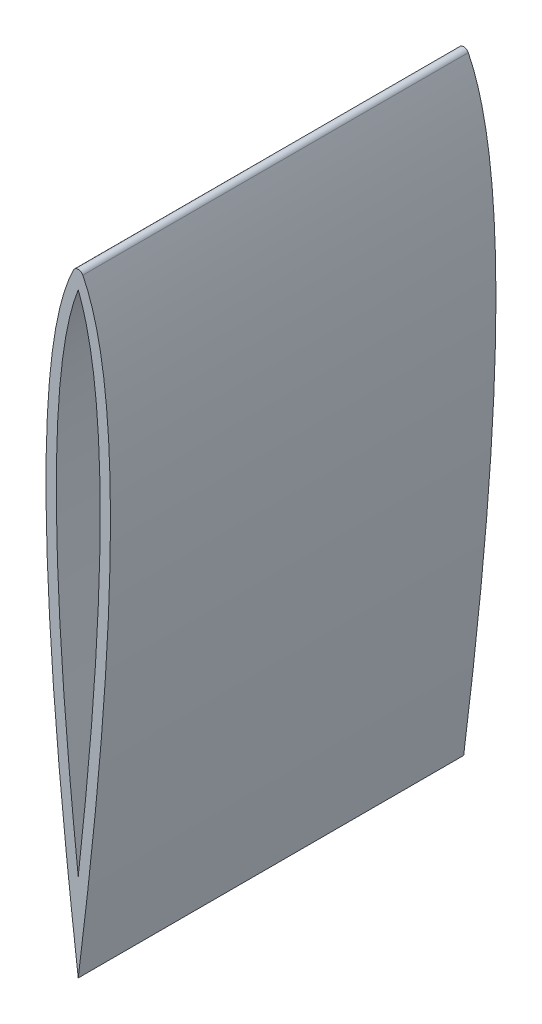
from build123d import *

# Parameters (mm, degrees)
BOSS_EXTRUDE1_DEPTH = 94.869


with BuildPart() as part:
    # Sketch1 → Boss-Extrude1 (new, symmetric)
    with BuildSketch(Plane.XY):
        with BuildLine():
            ThreePointArc((-2.267771894, 148.348367024), (0, 149.744334404), (2.267771894, 148.348367024))
            add(Edge.make_bspline(
                [(2.267771894, 148.348367024), (30.572440123, 92.24111101), (0, -152.4)],
                knots=[0, 0, 0, 1, 1, 1], degree=2))
            add(Edge.make_bspline(
                [(-2.267771894, 148.348367024), (-30.572440123, 92.24111101), (0, -152.4)],
                knots=[0, 0, 0, 1, 1, 1], degree=2))
        make_face()
        with BuildLine():
            add(Edge.make_bspline(
                [(0, 140.978035645), (3.918482074, 131.156065717), (8.169378172, 106.05556313), (10.242574642, 81.433345605), (11.145665597, 45.040166844), (8.163737965, -35.508846412), (0, -109.12531842)],
                knots=[0.045526815, 0.045526815, 0.045526815, 0.20753057, 0.315533073, 0.423535576, 0.585539331, 0.909546841, 0.909546841, 0.909546841], degree=2))
            add(Edge.make_bspline(
                [(0, -109.12531842), (-8.163737965, -35.508846412), (-11.145665597, 45.040166844), (-10.242574642, 81.433345605), (-8.169378172, 106.05556313), (-3.918482074, 131.156065717), (0, 140.978035645)],
                knots=[0.045526815, 0.045526815, 0.045526815, 0.369534325, 0.53153808, 0.639540583, 0.747543086, 0.909546841, 0.909546841, 0.909546841], degree=2))
        make_face(mode=Mode.SUBTRACT)
    extrude(amount=BOSS_EXTRUDE1_DEPTH, both=True)


solid = part.part
